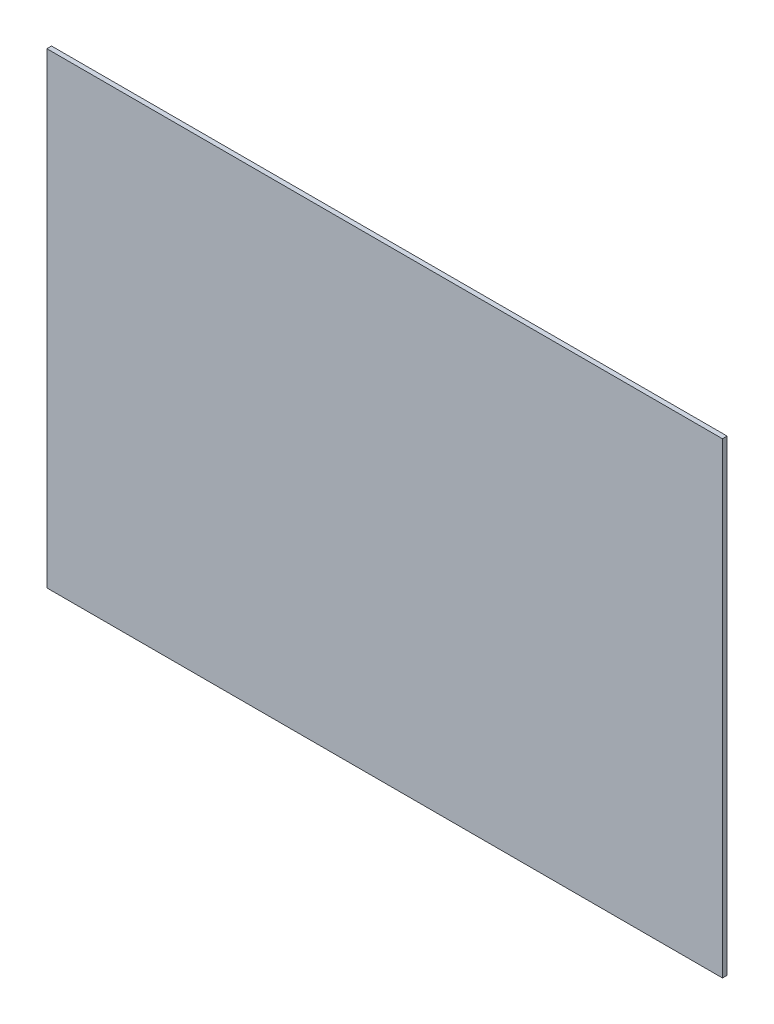
from build123d import *

# Parameters (mm, degrees)
ESQUISSE1_W        = 434
ESQUISSE1_H        = 300
BOSS_EXTRU_1_DEPTH = 3


with BuildPart() as part:
    # Esquisse1 → Boss.-Extru.1 (new body)
    with BuildSketch(Plane.XY):
        Rectangle(ESQUISSE1_W, ESQUISSE1_H)
    extrude(amount=BOSS_EXTRU_1_DEPTH)


solid = part.part
